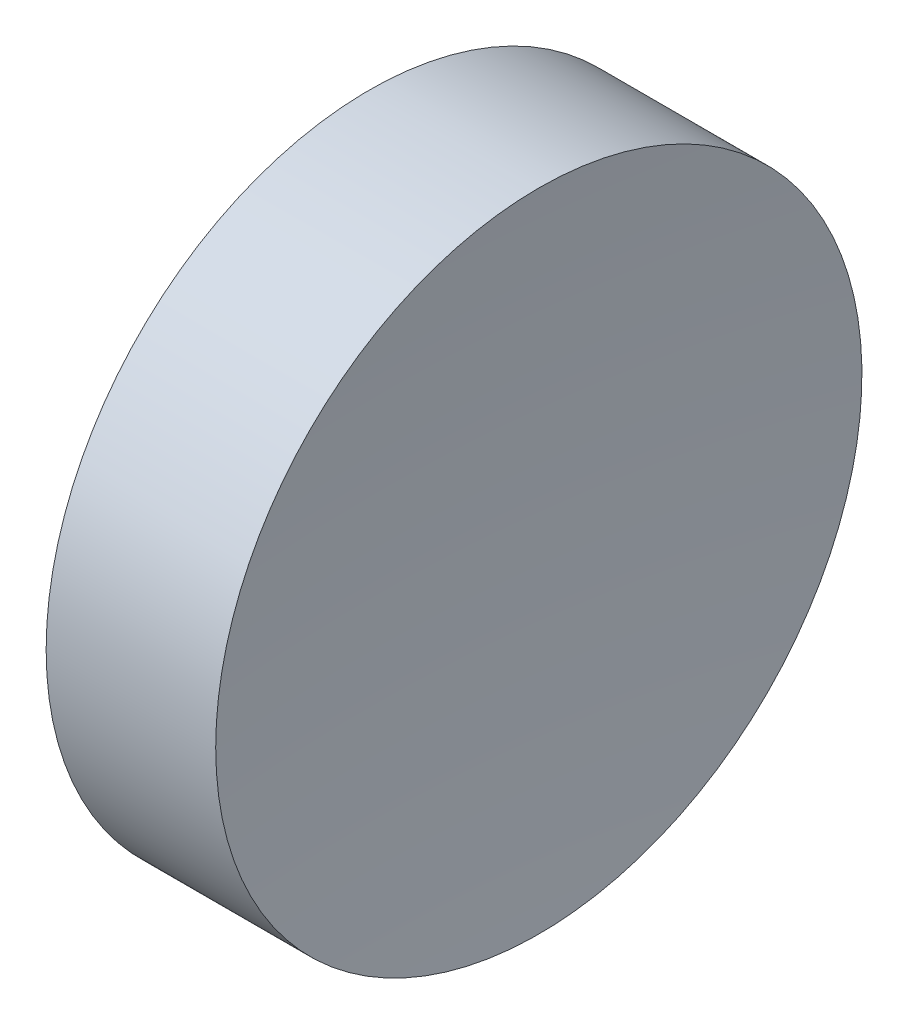
from build123d import *


with BuildPart() as part:
    # 草图1 → 旋转1 (revolve)
    with BuildSketch(Plane.XY):
        with BuildLine():
            Line((57.546327767, 34.689010562), (57.546327767, 40.939010562))
            Line((57.546327767, 40.939010562), (60.82590393, 40.939010562))
            ThreePointArc((60.82590393, 40.939010562), (60.616256737, 37.817135512), (60.546327767, 34.689010562))
            Line((60.546327767, 34.689010562), (57.546327767, 34.689010562))
        make_face()
    revolve(axis=Axis((54.492571501, 34.689010562, 0), (1, 0, 0)))


solid = part.part
